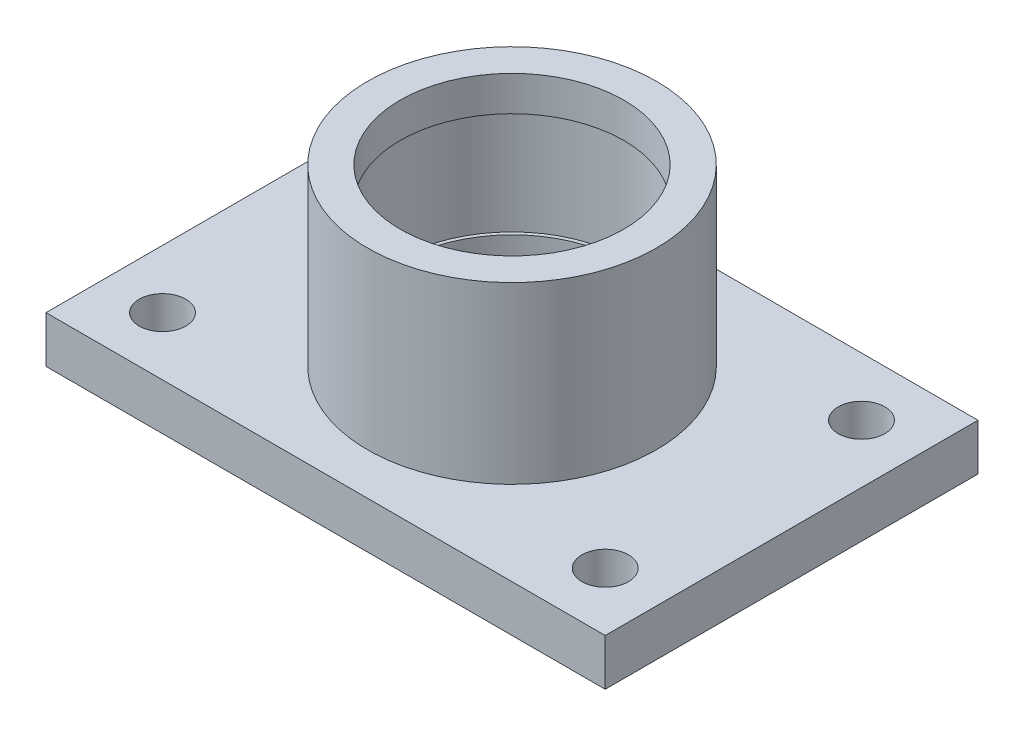
from build123d import *

# Parameters (mm, degrees)
SKETCH1_W           = 240
SKETCH1_H           = 160
BOSS_EXTRUDE2_DEPTH = 20
SKETCH5_R           = 10
CUT_EXTRUDE2_DEPTH  = 20
SKETCH6_W           = 220
SKETCH6_H           = 140
CUT_EXTRUDE3_DEPTH  = 3
SKETCH9_R           = 3
CUT_EXTRUDE4_DEPTH  = 10


with BuildPart() as part:
    # Sketch1 → Boss-Extrude2 (new body)
    with BuildSketch(Plane(origin=(0, 0, 0), x_dir=(1, 0, 0), z_dir=(0, 1, 0))):
        Rectangle(SKETCH1_W, SKETCH1_H)
    extrude(amount=BOSS_EXTRUDE2_DEPTH)

    # Sketch3 → Revolve1 (revolve)
    with BuildSketch(Plane.XY):
        Polygon((48, 20), (48, 35), (49.5, 35), (49.5, 80), (48, 80), (48, 95), (62, 95), (62, 20), align=None)
    revolve(axis=Axis((0, -30.427567953, 0), (0, 1, 0)))

    # Sketch5 → Cut-Extrude2 (cut)
    with BuildSketch(Plane.XZ):
        with Locations((95, 55)):
            Circle(SKETCH5_R)
        with Locations((-95, 55)):
            Circle(SKETCH5_R)
        with Locations((-95, -55)):
            Circle(SKETCH5_R)
        with Locations((95, -55)):
            Circle(SKETCH5_R)
    extrude(amount=-CUT_EXTRUDE2_DEPTH, mode=Mode.SUBTRACT)

    # Sketch6 → Cut-Extrude3 (cut)
    with BuildSketch(Plane.XZ):
        Rectangle(SKETCH6_W, SKETCH6_H)
    extrude(amount=-CUT_EXTRUDE3_DEPTH, mode=Mode.SUBTRACT)

    # Sketch9 → Cut-Extrude4 (cut)
    with BuildSketch(Plane(origin=(0, 20, 0), x_dir=(1, 0, 0), z_dir=(0, 1, 0))):
        with Locations((12, 0)):
            Circle(SKETCH9_R)
    extrude(amount=-CUT_EXTRUDE4_DEPTH, mode=Mode.SUBTRACT)


solid = part.part
